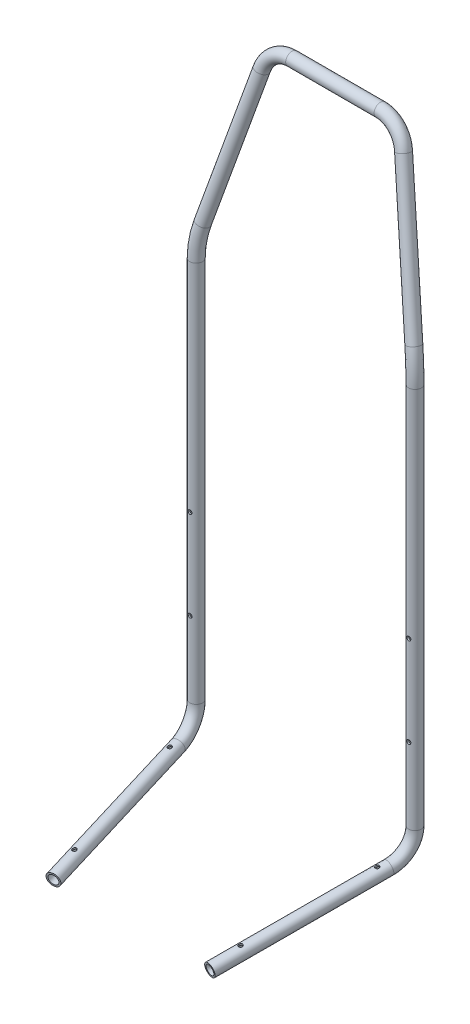
from build123d import *

# Parameters (mm, degrees)
SKIZZE5_R                            = 10.65
SKIZZE5_R_2                          = 7.95
SKIZZE9_R                            = 3.3
SCHNITT_LINEAR_AUSTRAGEN1_DEPTH      = 30
SKIZZE5_2_R                          = 10.65
SKIZZE5_2_R_2                        = 7.95
SKIZZE14_R                           = 10.65
SKIZZE14_R_2                         = 7.95
SKIZZE12_R                           = 3.3
SCHNITT_LINEAR_AUSTRAGEN2_DEPTH      = 1043.285650966
SCHNITT_LINEAR_AUSTRAGEN2_DEPTH_BACK = 72.615346428


with BuildPart() as part:
    # Austragung1: sweep along a curve in space
    with BuildLine() as austragung1_path:
        Line((183, -450, 0), (183, 123.020488578, 0))
        ThreePointArc((183, 123.020488578, 0), (181.37309799, 149.70195357, -1.143356011), (176.528337187, 175.793910825, -4.548162417))
        Line((176.528337187, 175.793910825, -4.548162417), (118.63960725, 406.519271688, -45.23126867))
        ThreePointArc((118.63960725, 406.519271688, -45.23126867), (102.341282328, 431.321079631, -49.604496581), (73.982613242, 440.953893118, -51.303021499))
        Line((73.982613242, 440.953893118, -51.303021499), (-73.982613242, 440.953893118, -51.303021499))
        ThreePointArc((-73.982613242, 440.953893118, -51.303021499), (-102.341282328, 431.321079631, -49.604496581), (-118.63960725, 406.519271688, -45.23126867))
        Line((-118.63960725, 406.519271688, -45.23126867), (-176.528337187, 175.793910825, -4.548162417))
        ThreePointArc((-176.528337187, 175.793910825, -4.548162417), (-181.37309799, 149.70195357, -1.143356011), (-183, 123.020488578, 0))
        Line((-183, 123.020488578, 0), (-183, -450, 0))
    # Skizze5 → Austragung1 (sweep)
    with BuildSketch(Plane(origin=(0, -450, 0), x_dir=(1, 0, 0), z_dir=(0, 1, 0))):
        with Locations((-183, 0)):
            Circle(SKIZZE5_R)
        with Locations((-183, 0)):
            Circle(SKIZZE5_R_2, mode=Mode.SUBTRACT)
    sweep(path=austragung1_path.line)

    # Skizze9 → Schnitt-Linear austragen1 (cut, symmetric)
    with BuildSketch(Plane.XY):
        with Locations((-183, -390)):
            Circle(SKIZZE9_R)
        with Locations((-183, -240)):
            Circle(SKIZZE9_R)
        with Locations((183, -240)):
            Circle(SKIZZE9_R)
        with Locations((183, -390)):
            Circle(SKIZZE9_R)
    extrude(amount=SCHNITT_LINEAR_AUSTRAGEN1_DEPTH, both=True, mode=Mode.SUBTRACT)

    # Austragung2: sweep along a curve in space
    with BuildLine() as austragung2_path:
        Line((-183, -450, 0), (-183, -516.296330402, 0))
        ThreePointArc((-183, -516.296330402, 0), (-181.096281897, -545.911720728, 10.63249844), (-176.279178305, -561.618717312, 37.536611159))
        Line((-176.279178305, -561.618717312, 37.536611159), (-130.9055467, -606.303021499, 290.953893118))
    # Skizze5_2 → Austragung2 (sweep)
    with BuildSketch(Plane(origin=(0, -450, 0), x_dir=(1, 0, 0), z_dir=(0, 1, 0))):
        with Locations((-183, 0)):
            Circle(SKIZZE5_2_R)
        with Locations((-183, 0)):
            Circle(SKIZZE5_2_R_2, mode=Mode.SUBTRACT)
    sweep(path=austragung2_path.line)

    # Austragung3: sweep along a curve in space
    with BuildLine() as austragung3_path:
        Line((183, -450, 0), (183, -516.296330402, 0))
        ThreePointArc((183, -516.296330402, 0), (181.096281897, -545.911720728, 10.63249844), (176.279178305, -561.618717312, 37.536611159))
        Line((176.279178305, -561.618717312, 37.536611159), (130.9055467, -606.303021499, 290.953893118))
    # Skizze14 → Austragung3 (sweep)
    with BuildSketch(Plane.XZ.offset(450)):
        with Locations((183, 0)):
            Circle(SKIZZE14_R)
        with Locations((183, 0)):
            Circle(SKIZZE14_R_2, mode=Mode.SUBTRACT)
    sweep(path=austragung3_path.line)

    # Skizze12 → Schnitt-Linear austragen2 (cut, two sides)
    with BuildSketch(Plane(origin=(0, -538.264702268, -94.910589773), x_dir=(1, 0, 0), z_dir=(0, 0.984807753, 0.173648178))) as schnitt_linear_austragen2_sk:
        with Locations(Location((173.67445564, -149.262528791, 0), (0, 0, 270))):  # turned: the seam where the file's is
            Circle(SKIZZE12_R)
        with Locations(Location((138.944820107, -346.224079393, 0), (0, 0, 270))):  # turned: the seam where the file's is
            Circle(SKIZZE12_R)
        with Locations(Location((-138.944820107, -346.224079393, 0), (0, 0, 270))):  # turned: the seam where the file's is
            Circle(SKIZZE12_R)
        with Locations(Location((-173.67445564, -149.262528791, 0), (0, 0, 270))):  # turned: the seam where the file's is
            Circle(SKIZZE12_R)
    extrude(amount=SCHNITT_LINEAR_AUSTRAGEN2_DEPTH, mode=Mode.SUBTRACT)
    extrude(schnitt_linear_austragen2_sk.sketch, amount=-SCHNITT_LINEAR_AUSTRAGEN2_DEPTH_BACK, mode=Mode.SUBTRACT)


solid = part.part
